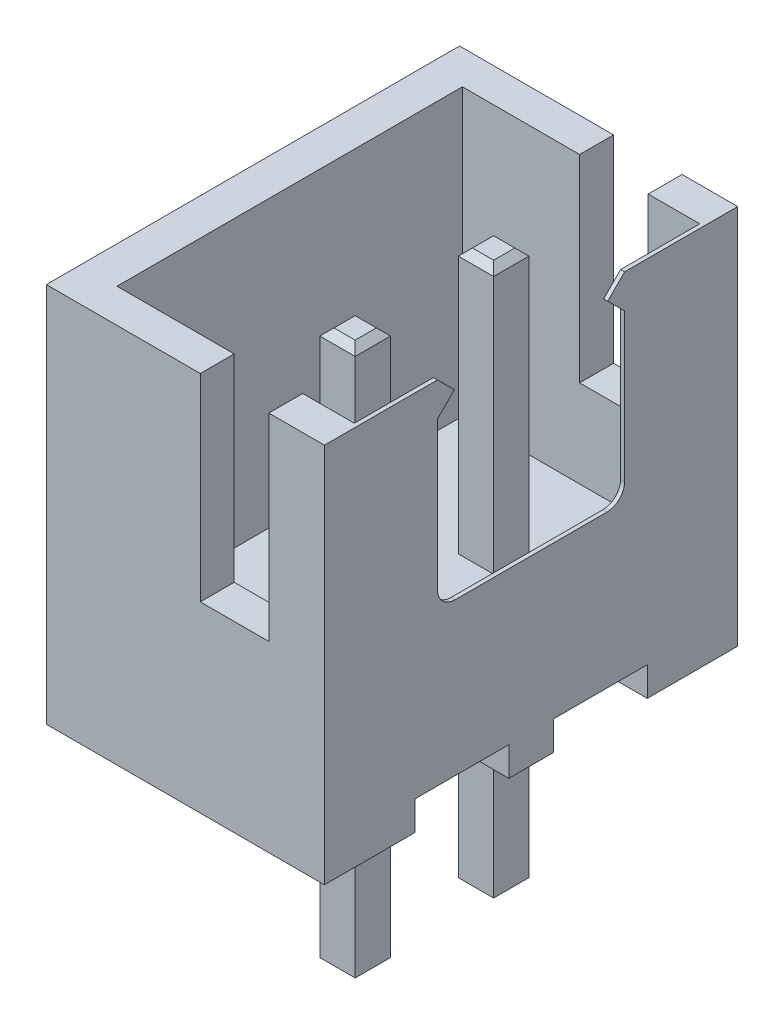
from build123d import *

# Parameters (mm, degrees)
SKETCH1_W           = 6.8453
SKETCH1_H           = 7.4295
BOSS_EXTRUDE1_DEPTH = 5
SKETCH2_W           = 5.8039
SKETCH2_H           = 0.127
CUT_EXTRUDE1_DEPTH  = 5.7277
CUT_EXTRUDE2_DEPTH  = 1.6891
CUT_EXTRUDE3_DEPTH  = 1.6891
SKETCH5_W           = 5
SKETCH5_H           = 4.1148
BOSS_EXTRUDE2_DEPTH = 0.127
SKETCH6_W           = 3.3147
SKETCH6_H           = 0.127
CUT_EXTRUDE4_DEPTH  = 6
CUT_EXTRUDE5_DEPTH  = 1.6891
CUT_EXTRUDE6_DEPTH  = 1.6891
SKETCH9_W           = 5
SKETCH9_H           = 1.6256
BOSS_EXTRUDE3_DEPTH = 0.127
SKETCH10_W          = 4.2672
SKETCH10_H          = 6.2103
CUT_EXTRUDE7_DEPTH  = 5.1308
CUT_EXTRUDE8_DEPTH  = 1.0724
SKETCH12_W          = 1.2319
SKETCH12_H          = 3.556
CUT_EXTRUDE9_DEPTH  = 1.6096
SKETCH13_W          = 1.2319
SKETCH13_H          = 3.556
CUT_EXTRUDE10_DEPTH = 8.4295
SKETCH14_W          = 0.635
SKETCH14_H          = 0.635
BOSS_EXTRUDE4_DEPTH = 3.5814
SKETCH15_W          = 0.635
SKETCH15_H          = 0.635
BOSS_EXTRUDE5_DEPTH = 3.5814
SKETCH16_W          = 0.635
SKETCH16_H          = 0.635
BOSS_EXTRUDE6_DEPTH = 4.7625
SKETCH17_W          = 0.635
SKETCH17_H          = 0.635
BOSS_EXTRUDE7_DEPTH = 4.7625
DRAFT1_ANGLE        = 45
DRAFT2_ANGLE        = 45
CHAMFER1_SIZE       = 0.127
FILLET1_R           = 0.3175


with BuildPart() as part:
    # Sketch1 → Boss-Extrude1 (new body)
    with BuildSketch(Plane(origin=(-5.7277, 0, 0), x_dir=(0, -1, 0), z_dir=(-1, 0, 0))):
        with Locations((-3.42265, -3.71475)):
            Rectangle(SKETCH1_W, SKETCH1_H)
    extrude(amount=-BOSS_EXTRUDE1_DEPTH)

    # Sketch2 → Cut-Extrude1 (cut)
    with BuildSketch(Plane.ZY.offset(5.7277)):
        with Locations((-4.52755, 0.0635)):
            Rectangle(SKETCH2_W, SKETCH2_H)
    extrude(amount=-CUT_EXTRUDE1_DEPTH, mode=Mode.SUBTRACT)

    # Sketch3 → Cut-Extrude2 (cut)
    with BuildSketch(Plane.XY.offset(-1.6256)):
        Polygon((-5.7277, 0.127), (-3.3477, 0.127), (-5.7277, 0.762), align=None)
    extrude(amount=-CUT_EXTRUDE2_DEPTH, mode=Mode.SUBTRACT)

    # Sketch4 → Cut-Extrude3 (cut)
    with BuildSketch(Plane.XY.offset(-1.6256)):
        Polygon((-1.94, 0.127), (0, 0.127), (0, 0.762), align=None)
    extrude(amount=-CUT_EXTRUDE3_DEPTH, mode=Mode.SUBTRACT)

    # Sketch5 → Boss-Extrude2 (add)
    with BuildSketch(Plane.XZ.offset(-0.127)):
        with Locations((-3.2277, -5.3721)):
            Rectangle(SKETCH5_W, SKETCH5_H)
    extrude(amount=BOSS_EXTRUDE2_DEPTH)

    # Sketch6 → Cut-Extrude4 (cut, through all)
    with BuildSketch(Plane.ZY.offset(5.7277)):
        with Locations((-5.77215, 0.0635)):
            Rectangle(SKETCH6_W, SKETCH6_H)
    extrude(amount=-CUT_EXTRUDE4_DEPTH, mode=Mode.SUBTRACT)

    # Sketch7 → Cut-Extrude5 (cut)
    with BuildSketch(Plane.XY.offset(-4.1148)):
        Polygon((-5.7277, 0.127), (-3.3477, 0.127), (-5.7277, 0.762), align=None)
    extrude(amount=-CUT_EXTRUDE5_DEPTH, mode=Mode.SUBTRACT)

    # Sketch8 → Cut-Extrude6 (cut)
    with BuildSketch(Plane.XY.offset(-4.1148)):
        Polygon((-1.94, 0.127), (0, 0.127), (0, 0.762), align=None)
    extrude(amount=-CUT_EXTRUDE6_DEPTH, mode=Mode.SUBTRACT)

    # Sketch9 → Boss-Extrude3 (add)
    with BuildSketch(Plane.XZ.offset(-0.127)):
        with Locations((-3.2277, -6.6167)):
            Rectangle(SKETCH9_W, SKETCH9_H)
    extrude(amount=BOSS_EXTRUDE3_DEPTH)

    # Sketch10 → Cut-Extrude7 (cut)
    with BuildSketch(Plane(origin=(0, 6.8453, 0), x_dir=(-1, 0, 0), z_dir=(0, 1, 0))):
        with Locations((2.9337, -3.71475)):
            Rectangle(SKETCH10_W, SKETCH10_H)
    extrude(amount=-CUT_EXTRUDE7_DEPTH, mode=Mode.SUBTRACT)

    # Sketch11 → Cut-Extrude8 (cut, through all)
    with BuildSketch(Plane.ZY.offset(0.8001)):
        Polygon((-2.032, 6.8453), (-5.3975, 6.8453), (-4.7879, 6.2357), (-5.3975, 6.2357), (-5.3975, 3.2639), (-2.032, 3.2639), (-2.032, 6.2357), (-2.6416, 6.2357), align=None)
    extrude(amount=-CUT_EXTRUDE8_DEPTH, mode=Mode.SUBTRACT)

    # Sketch12 → Cut-Extrude9 (cut, through all)
    with BuildSketch(Plane(origin=(0, 0, -0.6096), x_dir=(-1, 0, 0), z_dir=(0, 0, -1))):
        with Locations((2.34365, 5.0673)):
            Rectangle(SKETCH12_W, SKETCH12_H)
    extrude(amount=-CUT_EXTRUDE9_DEPTH, mode=Mode.SUBTRACT)

    # Sketch13 → Cut-Extrude10 (cut, through all)
    with BuildSketch(Plane(origin=(0, 0, -7.4295), x_dir=(-1, 0, 0), z_dir=(0, 0, -1))):
        with Locations((2.34365, 5.0673)):
            Rectangle(SKETCH13_W, SKETCH13_H)
    extrude(amount=-CUT_EXTRUDE10_DEPTH, mode=Mode.SUBTRACT)

    # Sketch14 → Boss-Extrude4 (add)
    with BuildSketch(Plane.XZ.offset(-0.127)):
        with Locations((-2.6452, -4.95935)):
            Rectangle(SKETCH14_W, SKETCH14_H)
    extrude(amount=BOSS_EXTRUDE4_DEPTH)

    # Sketch15 → Boss-Extrude5 (add)
    with BuildSketch(Plane.XZ.offset(-0.127)):
        with Locations((-2.6452, -2.47015)):
            Rectangle(SKETCH15_W, SKETCH15_H)
    extrude(amount=BOSS_EXTRUDE5_DEPTH)

    # Sketch16 → Boss-Extrude6 (add)
    with BuildSketch(Plane(origin=(0, 1.7145, 0), x_dir=(-1, 0, 0), z_dir=(0, 1, 0))):
        with Locations((2.6452, -4.95935)):
            Rectangle(SKETCH16_W, SKETCH16_H)
    extrude(amount=BOSS_EXTRUDE6_DEPTH)

    # Sketch17 → Boss-Extrude7 (add)
    with BuildSketch(Plane(origin=(0, 1.7145, 0), x_dir=(-1, 0, 0), z_dir=(0, 1, 0))):
        with Locations((2.6452, -2.47015)):
            Rectangle(SKETCH17_W, SKETCH17_H)
    extrude(amount=BOSS_EXTRUDE7_DEPTH)

    # Draft1
    draft1_faces = [part.faces().sort_by_distance(p)[0] for p in [
        (-0.7639, 6.2357, -2.3368),
    ]]
    draft(draft1_faces, Plane(origin=(-0.7277, 3.2639, -2.032), x_dir=(-1, 0, 0), z_dir=(0, 0, -1)), DRAFT1_ANGLE)

    # Draft2
    draft2_faces = [part.faces().sort_by_distance(p)[0] for p in [
        (-0.7639, 6.2357, -5.0927),
    ]]
    draft(draft2_faces, Plane(origin=(-0.7277, 6.2357, -5.3975), x_dir=(1, 0, 0), z_dir=(0, 0, 1)), DRAFT2_ANGLE)

    # Chamfer1
    chamfer1_edges = [part.edges().sort_by_distance(p)[0] for p in [
        (-2.3277, -3.4544, -4.95935),
        (-2.6452, -3.4544, -4.64185),
        (-2.9627, -3.4544, -4.95935),
        (-2.6452, -3.4544, -5.27685),
        (-2.9627, -3.4544, -2.47015),
        (-2.6452, -3.4544, -2.78765),
        (-2.3277, -3.4544, -2.47015),
        (-2.6452, -3.4544, -2.15265),
        (-2.6452, 6.477, -4.64185),
        (-2.3277, 6.477, -4.95935),
        (-2.6452, 6.477, -5.27685),
        (-2.9627, 6.477, -4.95935),
        (-2.3277, 6.477, -2.47015),
        (-2.6452, 6.477, -2.78765),
        (-2.9627, 6.477, -2.47015),
        (-2.6452, 6.477, -2.15265),
    ]]
    chamfer(chamfer1_edges, length=CHAMFER1_SIZE)

    # Fillet1
    fillet1_edges = [part.edges().sort_by_distance(p)[0] for p in [
        (-0.7639, 3.2639, -2.032),
        (-0.7639, 3.2639, -5.3975),
    ]]
    fillet(fillet1_edges, radius=FILLET1_R)


solid = part.part
